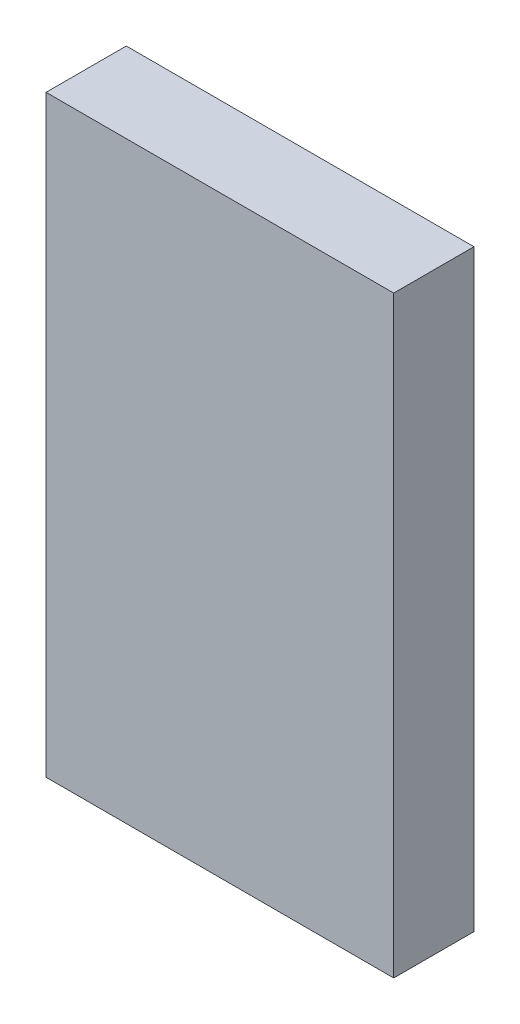
from build123d import *

# Parameters (mm, degrees)
SKETCH_1_W      = 13
SKETCH_1_H      = 22.18
EXTRUDE_1_DEPTH = 2
SKETCH_2_W      = 13
SKETCH_2_H      = 22.18
EXTRUDE_3_DEPTH = 1


with BuildPart() as part:
    # 草图1 → 凸台-拉伸1 (new body)
    with BuildSketch(Plane.XY):
        with Locations((3.5, -8.09)):
            Rectangle(SKETCH_1_W, SKETCH_1_H)
        Polygon((0, -5), (0, 0), (2, 0), (2, -3), (7, -3), (7, -5), (7, -9), (5, -9), (2, -9), (2, -16.18), (0, -16.18), (0, -9), (0, -7), (5, -7), (5, -5), (2, -5), align=None, mode=Mode.SUBTRACT)
    extrude(amount=-EXTRUDE_1_DEPTH)

    # 草图2 → 凸台-拉伸3 (add)
    with BuildSketch(Plane.XY):
        with Locations((3.5, -8.09)):
            Rectangle(SKETCH_2_W, SKETCH_2_H)
    extrude(amount=EXTRUDE_3_DEPTH)


solid = part.part
